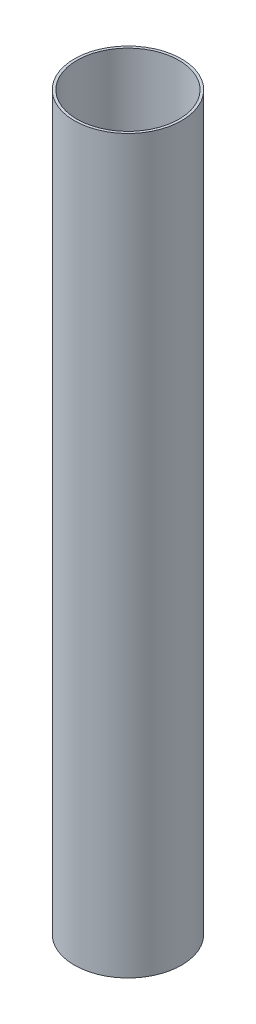
from build123d import *

# Parameters (mm, degrees)
SKETCH1_R           = 40.005
BOSS_EXTRUDE1_DEPTH = 546.1
SKETCH2_R           = 38.1
CUT_EXTRUDE1_DEPTH  = 546.1


with BuildPart() as part:
    # Sketch1 → Boss-Extrude1 (new body)
    with BuildSketch(Plane(origin=(0, 0, 0), x_dir=(1, 0, 0), z_dir=(0, 1, 0))):
        Circle(SKETCH1_R)
    extrude(amount=BOSS_EXTRUDE1_DEPTH)

    # Sketch2 → Cut-Extrude1 (cut)
    with BuildSketch(Plane(origin=(0, 546.1, 0), x_dir=(1, 0, 0), z_dir=(0, 1, 0))):
        Circle(SKETCH2_R)
    extrude(amount=-CUT_EXTRUDE1_DEPTH, mode=Mode.SUBTRACT)


solid = part.part
